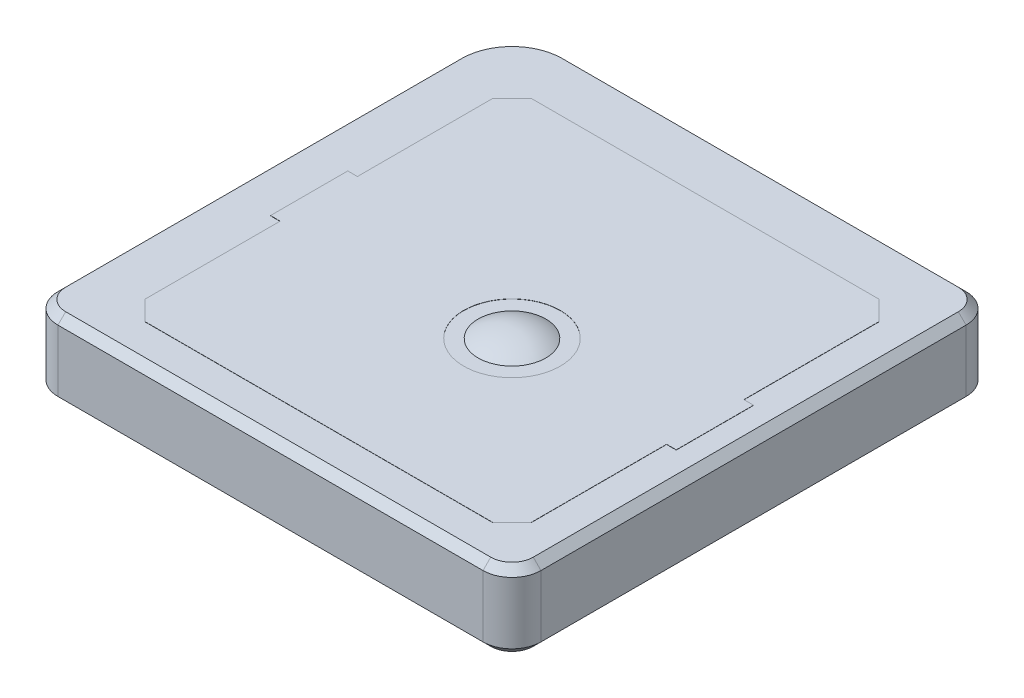
from build123d import *

# Parameters (mm, degrees)
BOSS_EXTRUDE1_DEPTH = 4
CHAMFER1_SIZE       = 0.4
BOSS_EXTRUDE2_START = 4
SKETCH3_R           = 2.5
BOSS_EXTRUDE2_DEPTH = 0.01


with BuildPart() as part:
    # Sketch1 → Boss-Extrude1 (new body)
    with BuildSketch(Plane(origin=(0, 0, 0), x_dir=(1, 0, 0), z_dir=(0, 1, 0))):
        with BuildLine():
            Line((-12.75, -10.75), (9.25, -10.75))
            ThreePointArc((9.25, -10.75), (10.310660172, -10.310660172), (10.75, -9.25))
            Line((10.75, -9.25), (10.75, 12.75))
            ThreePointArc((10.75, 12.75), (10.310660172, 13.810660172), (9.25, 14.25))
            Line((9.25, 14.25), (-11.25, 14.25))
            ThreePointArc((-11.25, 14.25), (-13.371320344, 13.371320344), (-14.25, 11.25))
            Line((-14.25, 11.25), (-14.25, -9.25))
            ThreePointArc((-14.25, -9.25), (-13.810660172, -10.310660172), (-12.75, -10.75))
        make_face()
    extrude(amount=BOSS_EXTRUDE1_DEPTH)

    # Chamfer1
    chamfer1_edges = [part.edges().sort_by_distance(p)[0] for p in [
        (-13.810660172, 4, 10.310660172),
        (-14.25, 0, -1),
        (-13.371320344, 0, -13.371320344),
        (-1.75, 4, 10.75),
        (10.310660172, 4, 10.310660172),
        (10.75, 4, -1.75),
        (10.310660172, 4, -13.810660172),
        (-1, 4, -14.25),
        (-13.371320344, 4, -13.371320344),
        (-14.25, 4, -1),
        (-1, 0, -14.25),
        (10.310660172, 0, -13.810660172),
        (10.75, 0, -1.75),
        (10.310660172, 0, 10.310660172),
        (-1.75, 0, 10.75),
        (-13.810660172, 0, 10.310660172),
    ]]
    chamfer(chamfer1_edges, length=CHAMFER1_SIZE)

    # Sketch2 → Revolve1 (revolve)
    with BuildSketch(Plane.XY):
        with BuildLine():
            Line((-3.215339078, 1.983898683), (-0.5, 1.983898683))
            Line((-0.5, 1.983898683), (-0.5, -2.4))
            Line((-0.5, -2.4), (0, -2.4))
            Line((0, -2.4), (0, 4.5))
            ThreePointArc((0, 4.5), (-2.041394819, 3.796209153), (-3.215339078, 1.983898683))
        make_face()
    revolve(axis=Axis((0, 5.892068095, 0), (0, -1, 0)))

    # Sketch3 → Boss-Extrude2 (add)
    with BuildSketch(Plane(origin=(0, 0, 0), x_dir=(1, 0, 0), z_dir=(0, 1, 0)).offset(BOSS_EXTRUDE2_START)):
        Polygon((-10.25, 11.25), (7.75, 11.25), (8.75, 10.25), (8.75, 3.25), (9.25, 3.25), (9.25, -0.75), (8.75, -0.75), (8.75, -7.75), (7.75, -8.75), (-10.25, -8.75), (-11.25, -7.75), (-11.25, -0.75), (-11.75, -0.75), (-11.75, 3.25), (-11.25, 3.25), (-11.25, 10.25), align=None)
        Circle(SKETCH3_R, mode=Mode.SUBTRACT)
    extrude(amount=BOSS_EXTRUDE2_DEPTH)


solid = part.part
